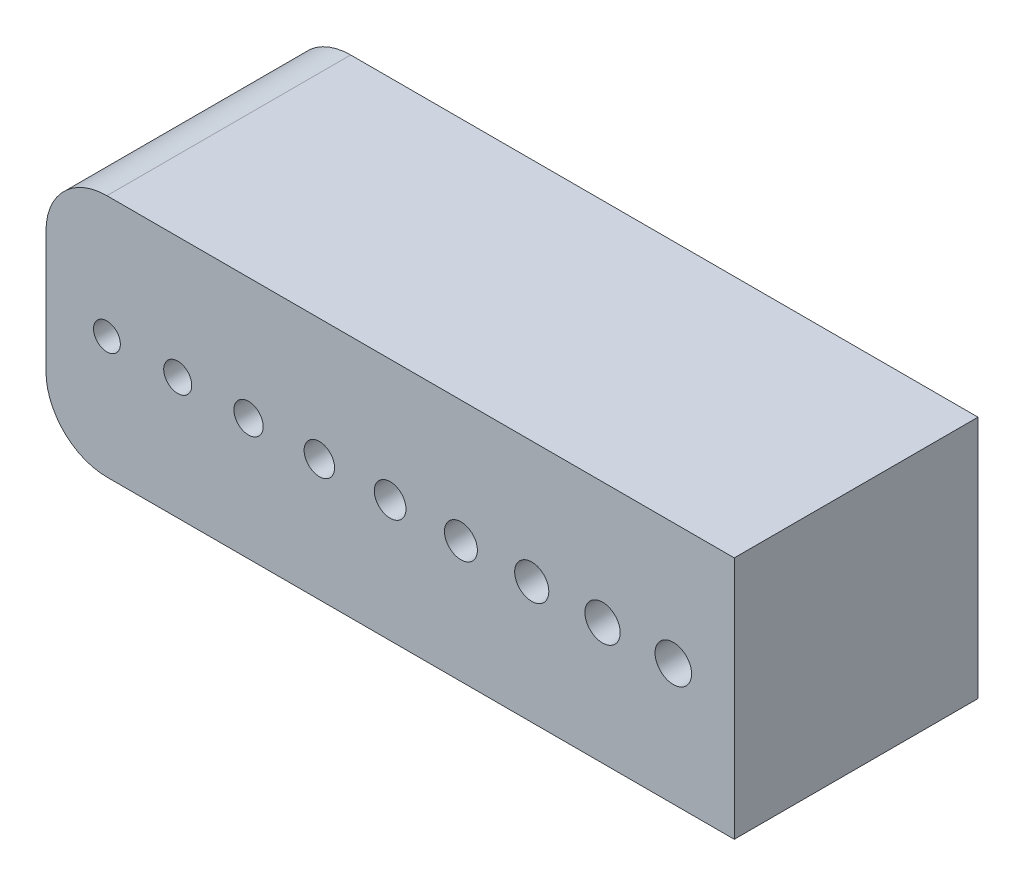
from build123d import *

# Parameters (mm, degrees)
SKETCH1_R           = 1.1
SKETCH1_R_2         = 1.15
SKETCH1_R_3         = 1.2
SKETCH1_R_4         = 1.25
SKETCH1_R_5         = 1.3
SKETCH1_R_6         = 1.35
SKETCH1_R_7         = 1.4
SKETCH1_R_8         = 1.45
SKETCH1_R_9         = 1.5
BOSS_EXTRUDE1_DEPTH = 20


with BuildPart() as part:
    # Sketch1 → Boss-Extrude1 (new body)
    with BuildSketch(Plane.XY):
        with BuildLine():
            Line((-23.238249128, -10), (28.238249128, -10))
            Line((28.238249128, -10), (28.238249128, 10))
            Line((28.238249128, 10), (-23.238249128, 10))
            ThreePointArc((-23.238249128, 10), (-26.773783034, 8.535533906), (-28.238249128, 5))
            Line((-28.238249128, 5), (-28.238249128, -5))
            ThreePointArc((-28.238249128, -5), (-26.773783034, -8.535533906), (-23.238249128, -10))
        make_face()
        with Locations((-23.238249128, 0)):
            Circle(SKETCH1_R, mode=Mode.SUBTRACT)
        with Locations((-17.428686846, 0)):
            Circle(SKETCH1_R_2, mode=Mode.SUBTRACT)
        with Locations((-11.619124564, 0)):
            Circle(SKETCH1_R_3, mode=Mode.SUBTRACT)
        with Locations((-5.809562282, 0)):
            Circle(SKETCH1_R_4, mode=Mode.SUBTRACT)
        Circle(SKETCH1_R_5, mode=Mode.SUBTRACT)
        with Locations((5.809562282, 0)):
            Circle(SKETCH1_R_6, mode=Mode.SUBTRACT)
        with Locations((11.619124564, 0)):
            Circle(SKETCH1_R_7, mode=Mode.SUBTRACT)
        with Locations((17.428686846, 0)):
            Circle(SKETCH1_R_8, mode=Mode.SUBTRACT)
        with Locations((23.238249128, 0)):
            Circle(SKETCH1_R_9, mode=Mode.SUBTRACT)
    extrude(amount=BOSS_EXTRUDE1_DEPTH)


solid = part.part
